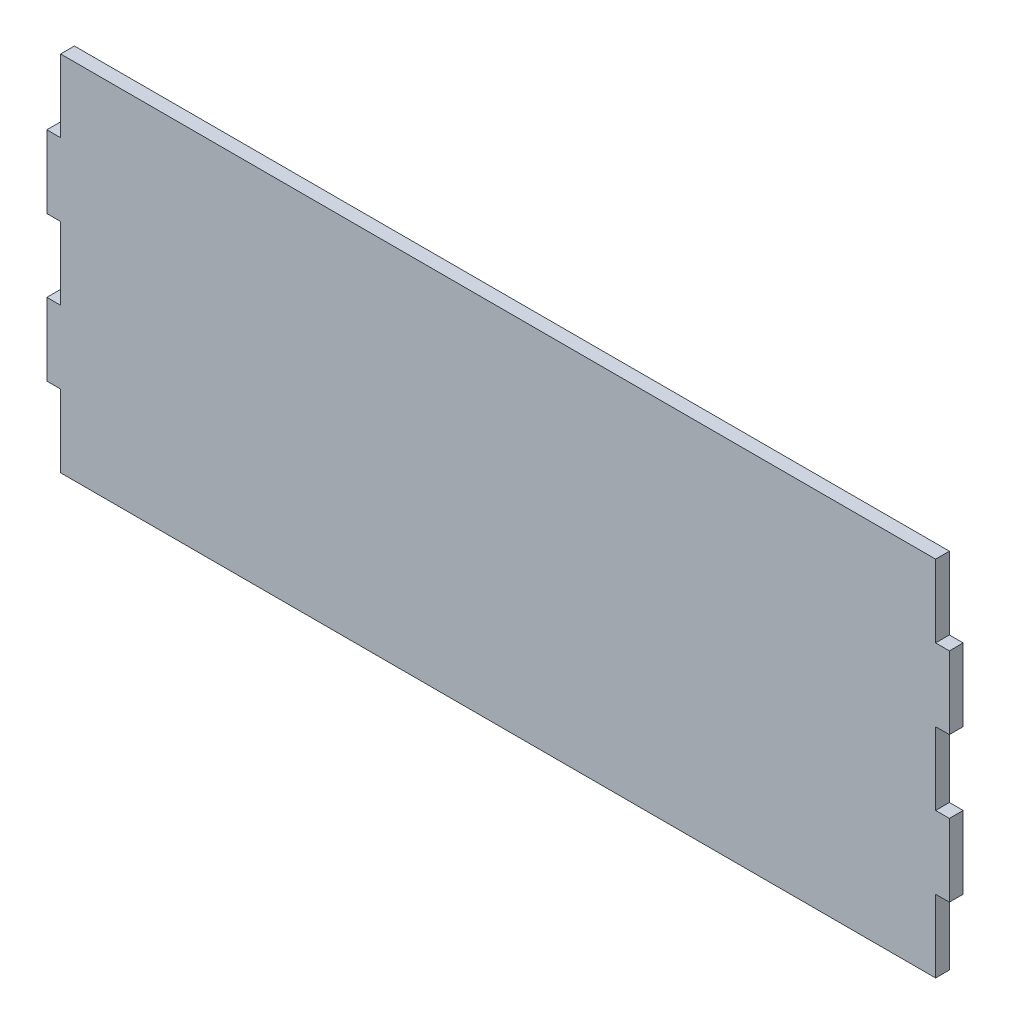
from build123d import *

# Parameters (mm, degrees)
BOSS_EXTRUDE1_DEPTH = 4.826


with BuildPart() as part:
    # Sketch2 → Boss-Extrude1 (new body)
    with BuildSketch(Plane.XY):
        Polygon((4.826, 76.2), (4.826, 50.8), (0, 50.8), (0, 25.4), (4.826, 25.4), (4.826, 0), (311.15, 0), (311.15, 25.4), (315.976, 25.4), (315.976, 50.8), (311.15, 50.8), (311.15, 76.2), (315.976, 76.2), (315.976, 101.6), (311.15, 101.6), (311.15, 127), (4.826, 127), (4.826, 101.6), (0, 101.6), (0, 76.2), align=None)
    extrude(amount=BOSS_EXTRUDE1_DEPTH)


solid = part.part
